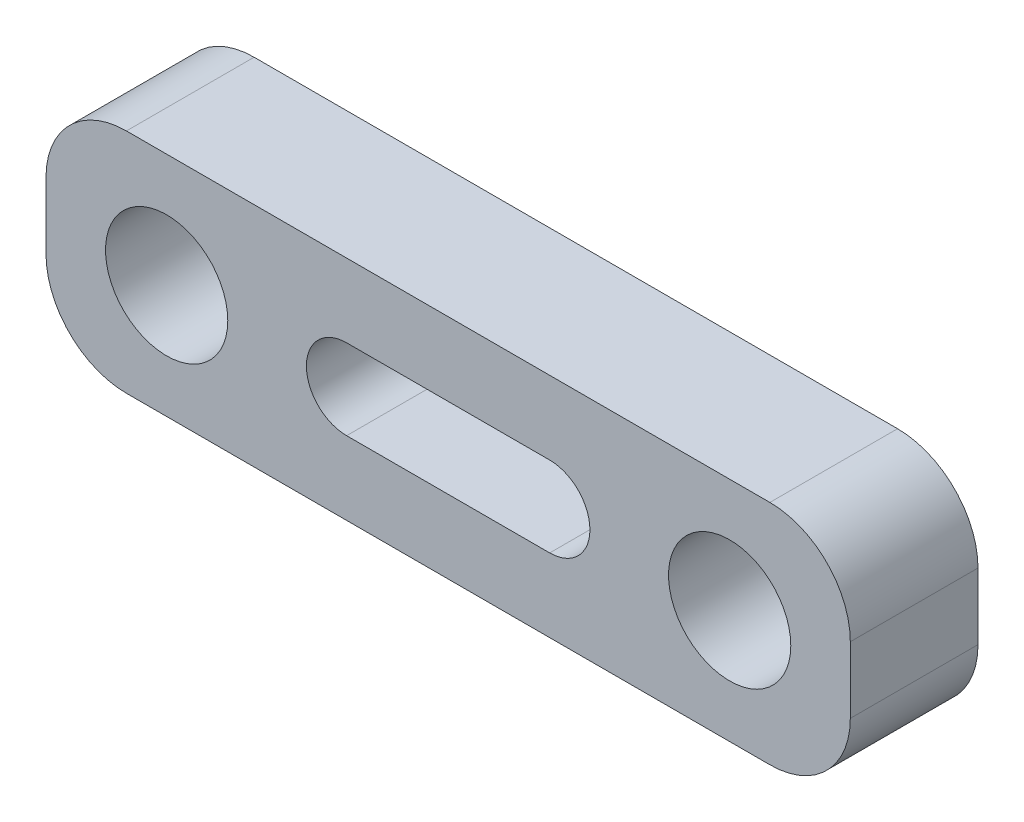
from build123d import *

# Parameters (mm, degrees)
SKETCH1_W           = 20
SKETCH1_H           = 5.65
BOSS_EXTRUDE1_DEPTH = 3.175
FILLET1_R           = 2
SKETCH2_R           = 1.52
CUT_EXTRUDE1_DEPTH  = 3.175


with BuildPart() as part:
    # Sketch1 → Boss-Extrude1 (new body)
    with BuildSketch(Plane.XY):
        Rectangle(SKETCH1_W, SKETCH1_H)
    extrude(amount=BOSS_EXTRUDE1_DEPTH)

    # Fillet1
    fillet1_edges = [part.edges().sort_by_distance(p)[0] for p in [
        (10, -2.825, 1.5875),
        (-10, -2.825, 1.5875),
        (-10, 2.825, 1.5875),
        (10, 2.825, 1.5875),
    ]]
    fillet(fillet1_edges, radius=FILLET1_R)

    # Sketch2 → Cut-Extrude1 (cut)
    with BuildSketch(Plane.XY.offset(3.175)):
        with Locations((-7, 0)):
            Circle(SKETCH2_R)
        with Locations((7, 0)):
            Circle(SKETCH2_R)
        with BuildLine():
            Line((-2.525, 1), (2.525, 1))
            ThreePointArc((2.525, 1), (3.525, 0), (2.525, -1))
            Line((2.525, -1), (-2.525, -1))
            ThreePointArc((-2.525, -1), (-3.525, 0), (-2.525, 1))
        make_face()
    extrude(amount=-CUT_EXTRUDE1_DEPTH, mode=Mode.SUBTRACT)


solid = part.part
